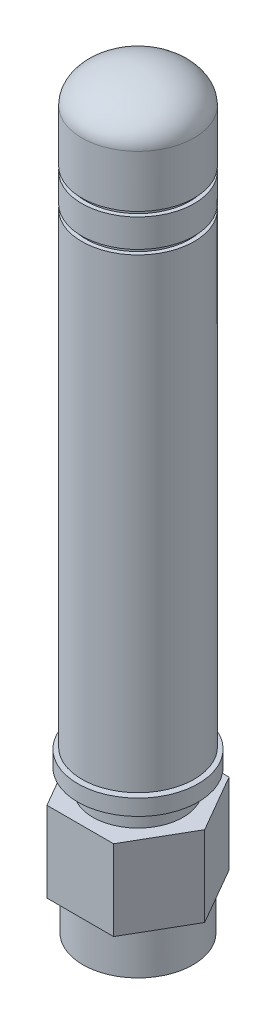
from build123d import *

# Parameters (mm, degrees)
SKETCH3_R           = 3.8354
BOSS_EXTRUDE1_DEPTH = 5.588


with BuildPart() as part:
    # Sketch1 → Revolve1 (revolve)
    with BuildSketch(Plane.XY):
        Polygon((2.0955, 3.81), (2.0955, 2.54), (4.18465, 2.54), (4.18465, 1.4351), (3.14325, 1.4351), (3.14325, 0), (3.8354, 0), (3.8354, -8.5344), (3.3528, -8.5344), (3.3528, -3.9624), (2.5273, -3.9624), (2.286, -3.9624), (2.286, -5.7531), (0.3683, -5.7531), (0.3683, 3.81), align=None)
    revolve(axis=Axis((0, 0, 0), (0, -1, 0)))

    # Sketch3 → Boss-Extrude1 (add)
    with BuildSketch(Plane(origin=(0, 0, 0), x_dir=(1, 0, 0), z_dir=(0, 1, 0))):
        Polygon((4.634044201, 0), (2.3170221, 4.0132), (-2.3170221, 4.0132), (-4.634044201, 0), (-2.3170221, -4.0132), (2.3170221, -4.0132), align=None)
        Circle(SKETCH3_R, mode=Mode.SUBTRACT)
    extrude(amount=-BOSS_EXTRUDE1_DEPTH)


with BuildPart() as body_2:
    # Sketch2 → Revolve2 (revolve)
    with BuildSketch(Plane.XY):
        with BuildLine():
            Line((2.2225, 2.667), (2.2225, 3.937))
            Line((2.2225, 3.937), (0.3683, 3.937))
            Line((0.3683, 3.937), (0.3683, 41.275))
            Line((0.3683, 41.275), (0, 41.275))
            Line((0, 41.275), (0, 43.561))
            add(Edge.make_bspline(
                [(3.90525, 41.275), (3.90525, 43.561), (0, 43.561)],
                knots=[0, 0, 0, 1.570796327, 1.570796327, 1.570796327], degree=2, weights=[1, 0.707106781, 1]))
            Line((3.90525, 41.275), (3.90525, 37.6555))
            Line((3.90525, 37.6555), (3.6195, 37.6555))
            Line((3.6195, 37.6555), (3.6195, 37.3253))
            Line((3.6195, 37.3253), (3.90525, 37.3253))
            Line((3.90525, 37.3253), (3.90525, 35.3695))
            Line((3.90525, 35.3695), (3.6195, 35.3695))
            Line((3.6195, 35.3695), (3.6195, 35.0393))
            Line((3.6195, 35.0393), (3.90525, 35.0393))
            Line((3.90525, 35.0393), (3.90525, 2.667))
            Line((3.90525, 2.667), (2.2225, 2.667))
        make_face()
    revolve(axis=Axis((0, 0, 0), (0, 1, 0)))


solid = Compound([part.part, body_2.part])
